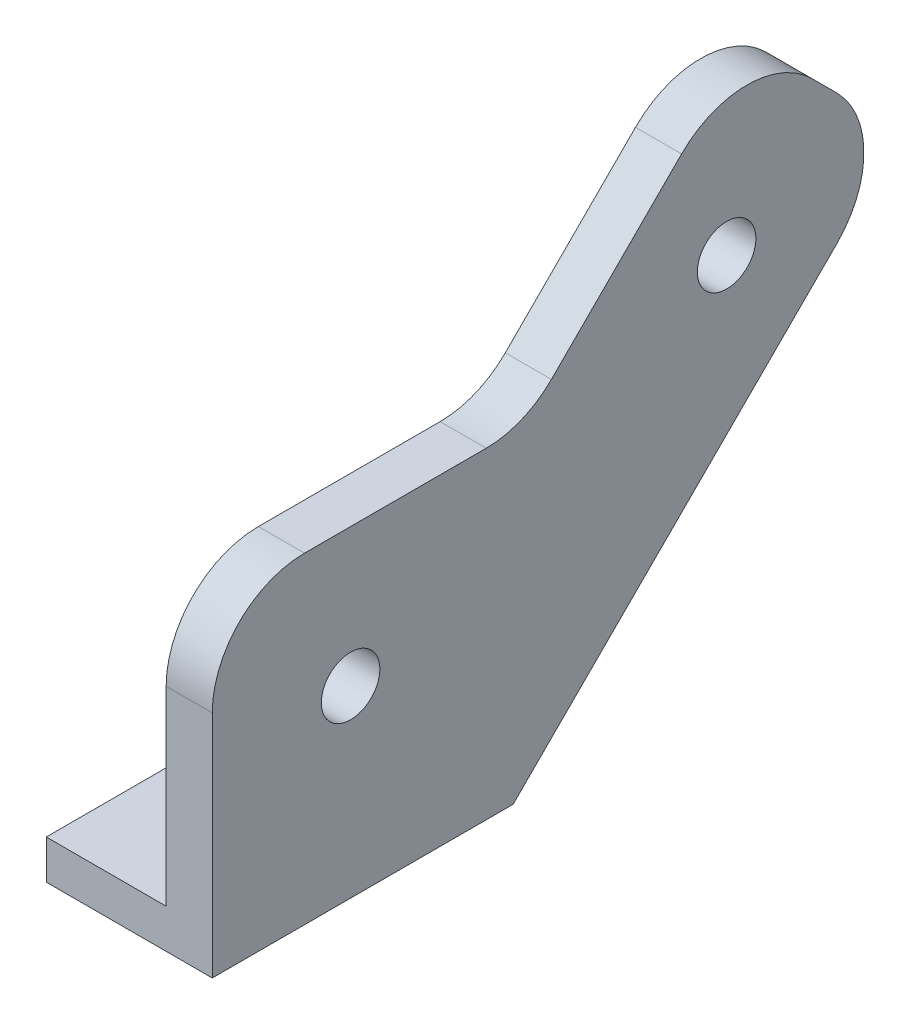
from build123d import *
from build123d.topology import SkipClean

# Parameters (mm, degrees)
SKETCH1_R                                       = 3.175
EXTRUDE_BODY_DEPTH                              = 5
INSET_BODY_DEPTH                                = 2
SKETCH3_R                                       = 6.175
CUT_HOLE_BOSS_DEPTH                             = 5
CUT_EXTRUDE2_DEPTH                              = 72.874270106
CUT_EXTRUDE2_DEPTH_BACK                         = 5
REAM_HOLE_R                                     = 3.175
SKETCH4_W                                       = 32.629490944
SKETCH4_H                                       = 4.242640687
BOSS_EXTRUDE1_DEPTH                             = 15
CSK_FOR_M3_FLAT_HEAD_MACHINE_SCREW1_D           = 3.4
CSK_FOR_M3_FLAT_HEAD_MACHINE_SCREW1_CSINK_D     = 6.3
CSK_FOR_M3_FLAT_HEAD_MACHINE_SCREW1_CSINK_ANGLE = 90


with BuildPart() as part:
    # Sketch1 → Extrude body (new body)
    with BuildSketch(Plane(origin=(0, 0, 0), x_dir=(0, 0, -1), z_dir=(1, 0, 0))):
        with BuildLine():
            Line((8.114294626, 0), (-24.515196318, 0))
            Line((-24.515196318, 0), (-24.515196318, 24.898772612))
            ThreePointArc((-24.515196318, 24.898772612), (-21.586264129, 31.969840424), (-14.515196318, 34.898772612))
            Line((-14.515196318, 34.898772612), (5.191949728, 34.898772612))
            ThreePointArc((5.191949728, 34.898772612), (9.018784051, 35.659977287), (12.26301754, 37.8277048))
            Line((12.26301754, 37.8277048), (26.380592117, 51.945279378))
            ThreePointArc((26.380592117, 51.945279378), (33.451659929, 54.874211566), (40.52272774, 51.945279378))
            Line((40.52272774, 51.945279378), (43.22008306, 49.247924058))
            ThreePointArc((43.22008306, 49.247924058), (46.149015248, 42.176856246), (43.22008306, 35.105788434))
            Line((43.22008306, 35.105788434), (8.114294626, 0))
        make_face()
        with Locations((31.264803682, 39.99)):
            Circle(SKETCH1_R, mode=Mode.SUBTRACT)
        with Locations((-9.515196318, 19.93)):
            Circle(SKETCH1_R, mode=Mode.SUBTRACT)
    extrude(amount=EXTRUDE_BODY_DEPTH)

    # Sketch2 → Inset body (cut)
    with BuildSketch(Plane(origin=(0, 0, 0), x_dir=(0, 0, -1), z_dir=(1, 0, 0))):
        with BuildLine():
            Line((-21.515196318, 24.898772612), (-21.515196318, 3))
            Line((-21.515196318, 3), (6.871653938, 3))
            Line((6.871653938, 3), (41.098762716, 37.227108778))
            ThreePointArc((41.098762716, 37.227108778), (43.149015248, 42.176856246), (41.098762716, 47.126603714))
            Line((41.098762716, 47.126603714), (38.401407397, 49.823959034))
            ThreePointArc((38.401407397, 49.823959034), (33.451659929, 51.874211566), (28.50191246, 49.823959034))
            Line((28.50191246, 49.823959034), (14.384337883, 35.706384457))
            ThreePointArc((14.384337883, 35.706384457), (10.166834349, 32.88833869), (5.191949728, 31.898772612))
            Line((5.191949728, 31.898772612), (-14.515196318, 31.898772612))
            ThreePointArc((-14.515196318, 31.898772612), (-19.464943786, 29.848520081), (-21.515196318, 24.898772612))
        make_face()
    extrude(amount=INSET_BODY_DEPTH, mode=Mode.SUBTRACT)

    # Sketch3 → Cut hole boss (add)
    with BuildSketch(Plane.ZY.offset(-2)):
        with Locations((9.515196318, 19.93)):
            Circle(SKETCH3_R)
        with Locations((-31.264803682, 39.99)):
            Circle(SKETCH3_R)
    extrude(amount=CUT_HOLE_BOSS_DEPTH)

    # Ream hole → Cut-Extrude2 (cut, two sides: drawn at the far end of the back side and taken through both)
    with SkipClean():  # the faces are left unmerged after this step: merging them gives an invalid solid
        with BuildSketch(Plane.ZY.offset(-CUT_EXTRUDE2_DEPTH_BACK)):
            with Locations((-31.264803682, 39.99)):
                Circle(REAM_HOLE_R)
            with Locations((9.515196318, 19.93)):
                Circle(REAM_HOLE_R)
        extrude(amount=CUT_EXTRUDE2_DEPTH + CUT_EXTRUDE2_DEPTH_BACK, mode=Mode.SUBTRACT)

    # Sketch4 → Boss-Extrude1 (add)
    with SkipClean():  # the faces are left unmerged after this step: merging them gives an invalid solid
        with BuildSketch(Plane.ZY.offset(-2)):
            with Locations((8.200450846, 2.121320344)):
                Rectangle(SKETCH4_W, SKETCH4_H)
        extrude(amount=BOSS_EXTRUDE1_DEPTH)

    # CSK for M3 Flat Head Machine Screw1 (through all)
    with Locations(Plane(origin=(0, 4.242640687, 0), x_dir=(1, 0, 0), z_dir=(0, 1, 0))):
        with Locations((-6.5, -8.200450846)):
            CounterSinkHole(CSK_FOR_M3_FLAT_HEAD_MACHINE_SCREW1_D / 2, CSK_FOR_M3_FLAT_HEAD_MACHINE_SCREW1_CSINK_D / 2, counter_sink_angle=CSK_FOR_M3_FLAT_HEAD_MACHINE_SCREW1_CSINK_ANGLE)


solid = part.part
